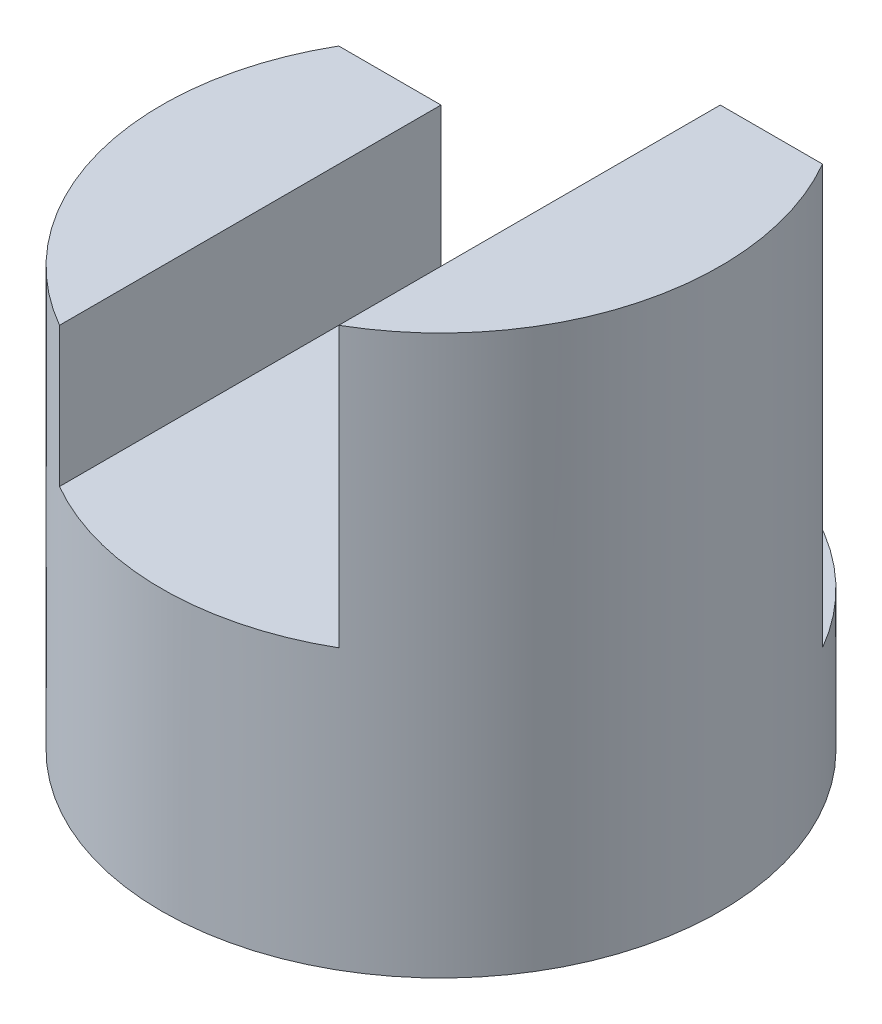
from build123d import *

# Parameters (mm, degrees)
SKETCH1_R           = 2
BOSS_EXTRUDE1_DEPTH = 4
CUT_EXTRUDE2_DEPTH  = 3
CUT_EXTRUDE3_DEPTH  = 5.5


with BuildPart() as part:
    # Sketch1 → Boss-Extrude1 (new body)
    with BuildSketch(Plane(origin=(0, 0, 0), x_dir=(1, 0, 0), z_dir=(0, 1, 0))):
        Circle(SKETCH1_R)
    extrude(amount=BOSS_EXTRUDE1_DEPTH)

    # Sketch3 → Cut-Extrude2 (cut)
    with BuildSketch(Plane(origin=(0, 4, 0), x_dir=(1, 0, 0), z_dir=(0, 1, 0))):
        with BuildLine():
            Line((-1.732050808, 1), (1.732050808, 1))
            ThreePointArc((1.732050808, 1), (0, 2), (-1.732050808, 1))
        make_face()
    extrude(amount=-CUT_EXTRUDE2_DEPTH, mode=Mode.SUBTRACT)

    # Sketch4 → Cut-Extrude3 (cut, symmetric)
    with BuildSketch(Plane.XY):
        Polygon((-2, 3), (-1, 3), (-1, 2), (1, 2), (1, 4), (-2, 4), align=None)
    extrude(amount=CUT_EXTRUDE3_DEPTH, both=True, mode=Mode.SUBTRACT)


solid = part.part
